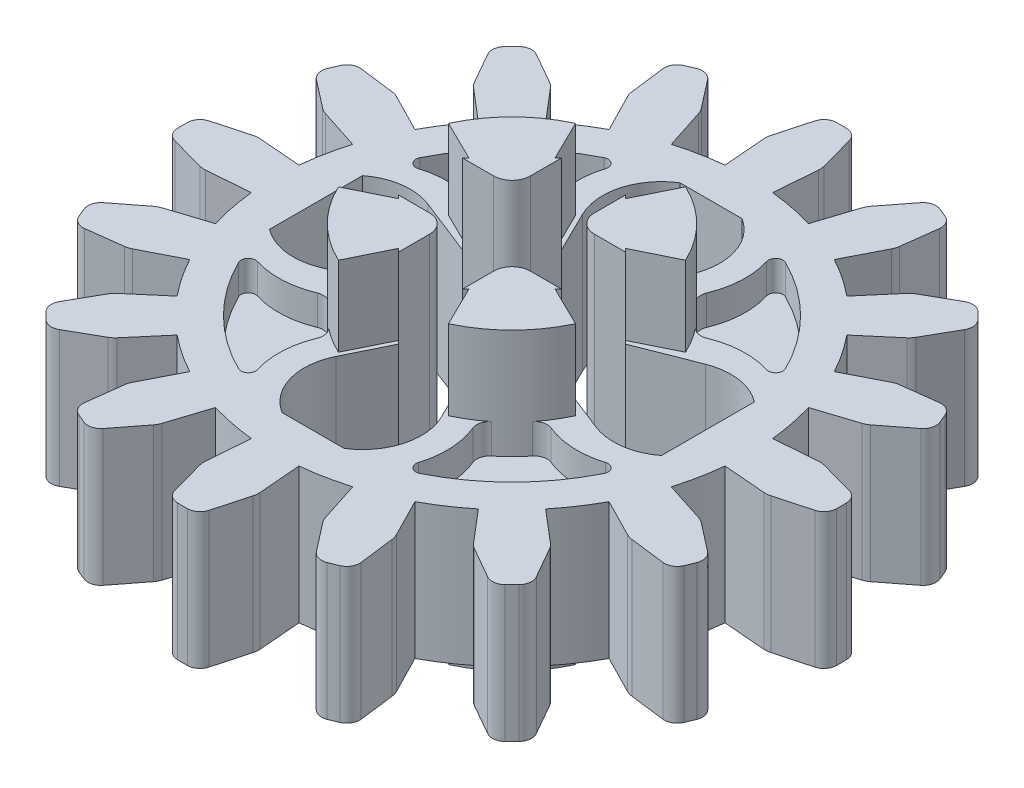
from build123d import *

# Parameters (mm, degrees)
BOSS_EXTRUDE1_DEPTH = 3.71
BOSS_EXTRUDE2_DEPTH = 2.1775
BOSS_EXTRUDE3_DEPTH = 2.1775
BOSS_EXTRUDE4_DEPTH = 2.1775
BOSS_EXTRUDE5_DEPTH = 2.1775
BOSS_EXTRUDE6_DEPTH = 2.1775
BOSS_EXTRUDE7_DEPTH = 2.1775
BOSS_EXTRUDE8_DEPTH = 2.1775
BOSS_EXTRUDE9_DEPTH = 2.1775
CUT_EXTRUDE1_DEPTH  = 0.815
CUT_EXTRUDE2_DEPTH  = 0.815
CUT_EXTRUDE3_DEPTH  = 0.815
CUT_EXTRUDE4_DEPTH  = 0.815
CUT_EXTRUDE5_DEPTH  = 0.815
CUT_EXTRUDE6_DEPTH  = 0.815
CUT_EXTRUDE7_DEPTH  = 0.815
CUT_EXTRUDE8_DEPTH  = 0.815
DRAFT1_ANGLE        = -44.305098292
DRAFT2_ANGLE        = -44.305098292
DRAFT3_ANGLE        = -44.305098292
DRAFT4_ANGLE        = -44.305098292
DRAFT5_ANGLE        = -44.305098292
DRAFT6_ANGLE        = -44.305098292
DRAFT7_ANGLE        = -44.305098292
DRAFT8_ANGLE        = -44.305098292
FILLET1_R           = 0.35
FILLET2_R           = 0.5


with BuildPart() as part:
    # Sketch1 → Boss-Extrude1 (new body)
    with BuildSketch(Plane(origin=(0, 1.855, 0), x_dir=(1, 0, 0), z_dir=(0, 1, 0))):
        with BuildLine():
            Line((3.071195766, 8.459772844), (2.258966578, 7.413472196))
            Line((2.258966578, 7.413472196), (1.874452153, 6.223859665))
            ThreePointArc((1.874452153, 6.223859665), (1.268087093, 6.375104323), (0.65, 6.467418341))
            Line((0.65, 6.467418341), (0.75, 7.71362431))
            Line((0.75, 7.71362431), (0.4, 8.991106717))
            ThreePointArc((0.4, 8.991106717), (0, 9), (-0.4, 8.991106717))
            Line((-0.4, 8.991106717), (-0.75, 7.71362431))
            Line((-0.75, 7.71362431), (-0.65, 6.467418341))
            ThreePointArc((-0.65, 6.467418341), (-1.268087093, 6.375104323), (-1.874452153, 6.223859665))
            Line((-1.874452153, 6.223859665), (-2.258966578, 7.413472196))
            Line((-2.258966578, 7.413472196), (-3.071195766, 8.459772844))
            ThreePointArc((-3.071195766, 8.459772844), (-3.444150891, 8.314915793), (-3.810299392, 8.153626098))
            Line((-3.810299392, 8.153626098), (-3.644785876, 6.839447047))
            Line((-3.644785876, 6.839447047), (-3.075495545, 5.726371203))
            ThreePointArc((-3.075495545, 5.726371203), (-3.611206515, 5.40455248), (-4.113535958, 5.032774774))
            Line((-4.113535958, 5.032774774), (-4.924025971, 5.984686143))
            Line((-4.924025971, 5.984686143), (-6.074829818, 6.640515243))
            ThreePointArc((-6.074829818, 6.640515243), (-6.363961031, 6.363961031), (-6.640515243, 6.074829818))
            Line((-6.640515243, 6.074829818), (-5.984686143, 4.924025971))
            Line((-5.984686143, 4.924025971), (-5.032774774, 4.113535958))
            ThreePointArc((-5.032774774, 4.113535958), (-5.40455248, 3.611206515), (-5.726371203, 3.075495545))
            Line((-5.726371203, 3.075495545), (-6.839447047, 3.644785876))
            Line((-6.839447047, 3.644785876), (-8.153626098, 3.810299392))
            ThreePointArc((-8.153626098, 3.810299392), (-8.314915793, 3.444150891), (-8.459772844, 3.071195766))
            Line((-8.459772844, 3.071195766), (-7.413472196, 2.258966578))
            Line((-7.413472196, 2.258966578), (-6.223859665, 1.874452153))
            ThreePointArc((-6.223859665, 1.874452153), (-6.375104323, 1.268087093), (-6.467418341, 0.65))
            Line((-6.467418341, 0.65), (-7.71362431, 0.75))
            Line((-7.71362431, 0.75), (-8.991106717, 0.4))
            ThreePointArc((-8.991106717, 0.4), (-9, 0), (-8.991106717, -0.4))
            Line((-8.991106717, -0.4), (-7.71362431, -0.75))
            Line((-7.71362431, -0.75), (-6.467418341, -0.65))
            ThreePointArc((-6.467418341, -0.65), (-6.375104323, -1.268087093), (-6.223859665, -1.874452153))
            Line((-6.223859665, -1.874452153), (-7.413472196, -2.258966578))
            Line((-7.413472196, -2.258966578), (-8.459772844, -3.071195766))
            ThreePointArc((-8.459772844, -3.071195766), (-8.314915793, -3.444150891), (-8.153626098, -3.810299392))
            Line((-8.153626098, -3.810299392), (-6.839447047, -3.644785876))
            Line((-6.839447047, -3.644785876), (-5.726371203, -3.075495545))
            ThreePointArc((-5.726371203, -3.075495545), (-5.40455248, -3.611206515), (-5.032774774, -4.113535958))
            Line((-5.032774774, -4.113535958), (-5.984686143, -4.924025971))
            Line((-5.984686143, -4.924025971), (-6.640515243, -6.074829818))
            ThreePointArc((-6.640515243, -6.074829818), (-6.363961031, -6.363961031), (-6.074829818, -6.640515243))
            Line((-6.074829818, -6.640515243), (-4.924025971, -5.984686143))
            Line((-4.924025971, -5.984686143), (-4.113535958, -5.032774774))
            ThreePointArc((-4.113535958, -5.032774774), (-3.611206515, -5.40455248), (-3.075495545, -5.726371203))
            Line((-3.075495545, -5.726371203), (-3.644785876, -6.839447047))
            Line((-3.644785876, -6.839447047), (-3.810299392, -8.153626098))
            ThreePointArc((-3.810299392, -8.153626098), (-3.444150891, -8.314915793), (-3.071195766, -8.459772844))
            Line((-3.071195766, -8.459772844), (-2.258966578, -7.413472196))
            Line((-2.258966578, -7.413472196), (-1.874452153, -6.223859665))
            ThreePointArc((-1.874452153, -6.223859665), (-1.268087093, -6.375104323), (-0.65, -6.467418341))
            Line((-0.65, -6.467418341), (-0.75, -7.71362431))
            Line((-0.75, -7.71362431), (-0.4, -8.991106717))
            ThreePointArc((-0.4, -8.991106717), (0, -9), (0.4, -8.991106717))
            Line((0.4, -8.991106717), (0.75, -7.71362431))
            Line((0.75, -7.71362431), (0.65, -6.467418341))
            ThreePointArc((0.65, -6.467418341), (1.268087093, -6.375104323), (1.874452153, -6.223859665))
            Line((1.874452153, -6.223859665), (2.258966578, -7.413472196))
            Line((2.258966578, -7.413472196), (3.071195766, -8.459772844))
            ThreePointArc((3.071195766, -8.459772844), (3.444150891, -8.314915793), (3.810299392, -8.153626098))
            Line((3.810299392, -8.153626098), (3.644785876, -6.839447047))
            Line((3.644785876, -6.839447047), (3.075495545, -5.726371203))
            ThreePointArc((3.075495545, -5.726371203), (3.611206515, -5.40455248), (4.113535958, -5.032774774))
            Line((4.113535958, -5.032774774), (4.924025971, -5.984686143))
            Line((4.924025971, -5.984686143), (6.074829818, -6.640515243))
            ThreePointArc((6.074829818, -6.640515243), (6.363961031, -6.363961031), (6.640515243, -6.074829818))
            Line((6.640515243, -6.074829818), (5.984686143, -4.924025971))
            Line((5.984686143, -4.924025971), (5.032774774, -4.113535958))
            ThreePointArc((5.032774774, -4.113535958), (5.40455248, -3.611206515), (5.726371203, -3.075495545))
            Line((5.726371203, -3.075495545), (6.839447047, -3.644785876))
            Line((6.839447047, -3.644785876), (8.153626098, -3.810299392))
            ThreePointArc((8.153626098, -3.810299392), (8.314915793, -3.444150891), (8.459772844, -3.071195766))
            Line((8.459772844, -3.071195766), (7.413472196, -2.258966578))
            Line((7.413472196, -2.258966578), (6.223859665, -1.874452153))
            ThreePointArc((6.223859665, -1.874452153), (6.375104323, -1.268087093), (6.467418341, -0.65))
            Line((6.467418341, -0.65), (7.71362431, -0.75))
            Line((7.71362431, -0.75), (8.991106717, -0.4))
            ThreePointArc((8.991106717, -0.4), (9, 0), (8.991106717, 0.4))
            Line((8.991106717, 0.4), (7.71362431, 0.75))
            Line((7.71362431, 0.75), (6.467418341, 0.65))
            ThreePointArc((6.467418341, 0.65), (6.375104323, 1.268087093), (6.223859665, 1.874452153))
            Line((6.223859665, 1.874452153), (7.413472196, 2.258966578))
            Line((7.413472196, 2.258966578), (8.459772844, 3.071195766))
            ThreePointArc((8.459772844, 3.071195766), (8.314915793, 3.444150891), (8.153626098, 3.810299392))
            Line((8.153626098, 3.810299392), (6.839447047, 3.644785876))
            Line((6.839447047, 3.644785876), (5.726371203, 3.075495545))
            ThreePointArc((5.726371203, 3.075495545), (5.40455248, 3.611206515), (5.032774774, 4.113535958))
            Line((5.032774774, 4.113535958), (5.984686143, 4.924025971))
            Line((5.984686143, 4.924025971), (6.640515243, 6.074829818))
            ThreePointArc((6.640515243, 6.074829818), (6.363961031, 6.363961031), (6.074829818, 6.640515243))
            Line((6.074829818, 6.640515243), (4.924025971, 5.984686143))
            Line((4.924025971, 5.984686143), (4.113535958, 5.032774774))
            ThreePointArc((4.113535958, 5.032774774), (3.611206515, 5.40455248), (3.075495545, 5.726371203))
            Line((3.075495545, 5.726371203), (3.644785876, 6.839447047))
            Line((3.644785876, 6.839447047), (3.810299392, 8.153626098))
            ThreePointArc((3.810299392, 8.153626098), (3.444150891, 8.314915793), (3.071195766, 8.459772844))
        make_face()
        with BuildLine():
            Line((-3.788594059, 1.490521407), (-2.22406722, 0.875))
            Line((-2.22406722, 0.875), (-0.875, 0.875))
            Line((-0.875, 0.875), (-0.875, 2.22406722))
            Line((-0.875, 2.22406722), (-1.437479603, 3.368474429))
            ThreePointArc((-1.437479603, 3.368474429), (-1.540081076, 4.515086664), (-0.847139124, 5.434367977))
            Line((-0.847139124, 5.434367977), (0.847139124, 5.434367977))
            ThreePointArc((0.847139124, 5.434367977), (1.540081076, 4.515086664), (1.437479603, 3.368474429))
            Line((1.437479603, 3.368474429), (0.875, 2.22406722))
            Line((0.875, 2.22406722), (0.875, 0.875))
            Line((0.875, 0.875), (2.22406722, 0.875))
            Line((2.22406722, 0.875), (3.788594059, 1.490521407))
            ThreePointArc((3.788594059, 1.490521407), (4.599107529, 1.585970305), (5.351439887, 1.269681511))
            Line((5.351439887, 1.269681511), (5.351439887, -1.269681511))
            ThreePointArc((5.351439887, -1.269681511), (4.599107529, -1.585970305), (3.788594059, -1.490521407))
            Line((3.788594059, -1.490521407), (2.22406722, -0.875))
            Line((2.22406722, -0.875), (0.875, -0.875))
            Line((0.875, -0.875), (0.875, -2.22406722))
            Line((0.875, -2.22406722), (1.437479603, -3.368474429))
            ThreePointArc((1.437479603, -3.368474429), (1.540081076, -4.515086664), (0.847139124, -5.434367977))
            Line((0.847139124, -5.434367977), (-0.847139124, -5.434367977))
            ThreePointArc((-0.847139124, -5.434367977), (-1.540081076, -4.515086664), (-1.437479603, -3.368474429))
            Line((-1.437479603, -3.368474429), (-0.875, -2.22406722))
            Line((-0.875, -2.22406722), (-0.875, -0.875))
            Line((-0.875, -0.875), (-2.22406722, -0.875))
            Line((-2.22406722, -0.875), (-3.788594059, -1.490521407))
            ThreePointArc((-3.788594059, -1.490521407), (-4.599107529, -1.585970305), (-5.351439887, -1.269681511))
            Line((-5.351439887, -1.269681511), (-5.351439887, 1.269681511))
            ThreePointArc((-5.351439887, 1.269681511), (-4.599107529, 1.585970305), (-3.788594059, 1.490521407))
        make_face(mode=Mode.SUBTRACT)
    extrude(amount=-BOSS_EXTRUDE1_DEPTH)

    # Sketch2 → Boss-Extrude2 (add)
    with BuildSketch(Plane.XZ.offset(1.855)):
        with BuildLine():
            Line((-2.22406722, -1.004322756), (-2.22406722, -0.875))
            Line((-2.22406722, -0.875), (-0.875, -0.875))
            Line((-0.875, -0.875), (-0.875, -2.22406722))
            Line((-0.875, -2.22406722), (-1.004322756, -2.22406722))
            Line((-1.004322756, -2.22406722), (-1.502122, -3.236877356))
            ThreePointArc((-1.502122, -3.236877356), (-2.523266288, -2.523266288), (-3.236877356, -1.502122))
            Line((-3.236877356, -1.502122), (-2.22406722, -1.004322756))
        make_face()
    extrude(amount=BOSS_EXTRUDE2_DEPTH)

    # Sketch3 → Boss-Extrude3 (add)
    with BuildSketch(Plane(origin=(0, 1.855, 0), x_dir=(-1, 0, 0), z_dir=(0, 1, 0))):
        with BuildLine():
            Line((2.22406722, -0.875), (2.22406722, -1.004322756))
            Line((2.22406722, -1.004322756), (3.236877356, -1.502122))
            ThreePointArc((3.236877356, -1.502122), (2.523266288, -2.523266288), (1.502122, -3.236877356))
            Line((1.502122, -3.236877356), (1.004322756, -2.22406722))
            Line((1.004322756, -2.22406722), (0.875, -2.22406722))
            Line((0.875, -2.22406722), (0.875, -0.875))
            Line((0.875, -0.875), (2.22406722, -0.875))
        make_face()
    extrude(amount=BOSS_EXTRUDE3_DEPTH)

    # Sketch4 → Boss-Extrude4 (add)
    with BuildSketch(Plane.XZ.offset(1.855)):
        with BuildLine():
            Line((-1.004322756, 2.22406722), (-0.875, 2.22406722))
            Line((-0.875, 2.22406722), (-0.875, 0.875))
            Line((-0.875, 0.875), (-2.22406722, 0.875))
            Line((-2.22406722, 0.875), (-2.22406722, 1.004322756))
            Line((-2.22406722, 1.004322756), (-3.236877356, 1.502122))
            ThreePointArc((-3.236877356, 1.502122), (-2.523266288, 2.523266288), (-1.502122, 3.236877356))
            Line((-1.502122, 3.236877356), (-1.004322756, 2.22406722))
        make_face()
    extrude(amount=BOSS_EXTRUDE4_DEPTH)

    # Sketch5 → Boss-Extrude5 (add)
    with BuildSketch(Plane(origin=(0, 1.855, 0), x_dir=(-1, 0, 0), z_dir=(0, 1, 0))):
        with BuildLine():
            Line((0.875, 2.22406722), (1.004322756, 2.22406722))
            Line((1.004322756, 2.22406722), (1.502122, 3.236877356))
            ThreePointArc((1.502122, 3.236877356), (2.523266288, 2.523266288), (3.236877356, 1.502122))
            Line((3.236877356, 1.502122), (2.22406722, 1.004322756))
            Line((2.22406722, 1.004322756), (2.22406722, 0.875))
            Line((2.22406722, 0.875), (0.875, 0.875))
            Line((0.875, 0.875), (0.875, 2.22406722))
        make_face()
    extrude(amount=BOSS_EXTRUDE5_DEPTH)

    # Sketch6 → Boss-Extrude6 (add)
    with BuildSketch(Plane.XZ.offset(1.855)):
        with BuildLine():
            Line((2.22406722, 1.004322756), (2.22406722, 0.875))
            Line((2.22406722, 0.875), (0.875, 0.875))
            Line((0.875, 0.875), (0.875, 2.22406722))
            Line((0.875, 2.22406722), (1.004322756, 2.22406722))
            Line((1.004322756, 2.22406722), (1.502122, 3.236877356))
            ThreePointArc((1.502122, 3.236877356), (2.523266288, 2.523266288), (3.236877356, 1.502122))
            Line((3.236877356, 1.502122), (2.22406722, 1.004322756))
        make_face()
    extrude(amount=BOSS_EXTRUDE6_DEPTH)

    # Sketch7 → Boss-Extrude7 (add)
    with BuildSketch(Plane(origin=(0, 1.855, 0), x_dir=(-1, 0, 0), z_dir=(0, 1, 0))):
        with BuildLine():
            Line((-2.22406722, 0.875), (-2.22406722, 1.004322756))
            Line((-2.22406722, 1.004322756), (-3.236877356, 1.502122))
            ThreePointArc((-3.236877356, 1.502122), (-2.523266288, 2.523266288), (-1.502122, 3.236877356))
            Line((-1.502122, 3.236877356), (-1.004322756, 2.22406722))
            Line((-1.004322756, 2.22406722), (-0.875, 2.22406722))
            Line((-0.875, 2.22406722), (-0.875, 0.875))
            Line((-0.875, 0.875), (-2.22406722, 0.875))
        make_face()
    extrude(amount=BOSS_EXTRUDE7_DEPTH)

    # Sketch8 → Boss-Extrude8 (add)
    with BuildSketch(Plane(origin=(0, 1.855, 0), x_dir=(-1, 0, 0), z_dir=(0, 1, 0))):
        with BuildLine():
            Line((-0.875, -2.22406722), (-1.004322756, -2.22406722))
            Line((-1.004322756, -2.22406722), (-1.502122, -3.236877356))
            ThreePointArc((-1.502122, -3.236877356), (-2.523266288, -2.523266288), (-3.236877356, -1.502122))
            Line((-3.236877356, -1.502122), (-2.22406722, -1.004322756))
            Line((-2.22406722, -1.004322756), (-2.22406722, -0.875))
            Line((-2.22406722, -0.875), (-0.875, -0.875))
            Line((-0.875, -0.875), (-0.875, -2.22406722))
        make_face()
    extrude(amount=BOSS_EXTRUDE8_DEPTH)

    # Sketch9 → Boss-Extrude9 (add)
    with BuildSketch(Plane.XZ.offset(1.855)):
        with BuildLine():
            Line((1.004322756, -2.22406722), (0.875, -2.22406722))
            Line((0.875, -2.22406722), (0.875, -0.875))
            Line((0.875, -0.875), (2.22406722, -0.875))
            Line((2.22406722, -0.875), (2.22406722, -1.004322756))
            Line((2.22406722, -1.004322756), (3.236877356, -1.502122))
            ThreePointArc((3.236877356, -1.502122), (2.523266288, -2.523266288), (1.502122, -3.236877356))
            Line((1.502122, -3.236877356), (1.004322756, -2.22406722))
        make_face()
    extrude(amount=BOSS_EXTRUDE9_DEPTH)

    # Sketch10 → Cut-Extrude1 (cut)
    with BuildSketch(Plane(origin=(0, 1.855, 0), x_dir=(-1, 0, 0), z_dir=(0, 1, 0))):
        with BuildLine():
            ThreePointArc((2.950843011, 2.006557013), (3.832674353, 2.287198781), (4.753735255, 2.197571031))
            ThreePointArc((4.753735255, 2.197571031), (4.965100048, 2.259083289), (4.99190412, 2.477579))
            ThreePointArc((4.99190412, 2.477579), (3.940653781, 3.940653781), (2.477579, 4.99190412))
            ThreePointArc((2.477579, 4.99190412), (2.259083289, 4.965100048), (2.197571031, 4.753735255))
            ThreePointArc((2.197571031, 4.753735255), (2.287198781, 3.832674353), (2.006557013, 2.950843011))
            ThreePointArc((2.006557013, 2.950843011), (2.523266288, 2.523266288), (2.950843011, 2.006557013))
        make_face()
    extrude(amount=-CUT_EXTRUDE1_DEPTH, mode=Mode.SUBTRACT)

    # Sketch11 → Cut-Extrude2 (cut)
    with BuildSketch(Plane(origin=(0, 1.855, 0), x_dir=(-1, 0, 0), z_dir=(0, 1, 0))):
        with BuildLine():
            ThreePointArc((2.006557013, -2.950843011), (2.287198781, -3.832674353), (2.197571031, -4.753735255))
            ThreePointArc((2.197571031, -4.753735255), (2.259083289, -4.965100048), (2.477579, -4.99190412))
            ThreePointArc((2.477579, -4.99190412), (3.940653781, -3.940653781), (4.99190412, -2.477579))
            ThreePointArc((4.99190412, -2.477579), (4.965100048, -2.259083289), (4.753735255, -2.197571031))
            ThreePointArc((4.753735255, -2.197571031), (3.832674353, -2.287198781), (2.950843011, -2.006557013))
            ThreePointArc((2.950843011, -2.006557013), (2.523266288, -2.523266288), (2.006557013, -2.950843011))
        make_face()
    extrude(amount=-CUT_EXTRUDE2_DEPTH, mode=Mode.SUBTRACT)

    # Sketch12 → Cut-Extrude3 (cut)
    with BuildSketch(Plane(origin=(0, 1.855, 0), x_dir=(-1, 0, 0), z_dir=(0, 1, 0))):
        with BuildLine():
            ThreePointArc((-2.950843011, -2.006557013), (-3.832674353, -2.287198781), (-4.753735255, -2.197571031))
            ThreePointArc((-4.753735255, -2.197571031), (-4.965100048, -2.259083289), (-4.99190412, -2.477579))
            ThreePointArc((-4.99190412, -2.477579), (-3.940653781, -3.940653781), (-2.477579, -4.99190412))
            ThreePointArc((-2.477579, -4.99190412), (-2.259083289, -4.965100048), (-2.197571031, -4.753735255))
            ThreePointArc((-2.197571031, -4.753735255), (-2.287198781, -3.832674353), (-2.006557013, -2.950843011))
            ThreePointArc((-2.006557013, -2.950843011), (-2.523266288, -2.523266288), (-2.950843011, -2.006557013))
        make_face()
    extrude(amount=-CUT_EXTRUDE3_DEPTH, mode=Mode.SUBTRACT)

    # Sketch13 → Cut-Extrude4 (cut)
    with BuildSketch(Plane.XZ.offset(1.855)):
        with BuildLine():
            ThreePointArc((4.753735255, -2.197571031), (3.832674353, -2.287198781), (2.950843011, -2.006557013))
            ThreePointArc((2.950843011, -2.006557013), (2.523266288, -2.523266288), (2.006557013, -2.950843011))
            ThreePointArc((2.006557013, -2.950843011), (2.287198781, -3.832674353), (2.197571031, -4.753735255))
            ThreePointArc((2.197571031, -4.753735255), (2.259083289, -4.965100048), (2.477579, -4.99190412))
            ThreePointArc((2.477579, -4.99190412), (3.940653781, -3.940653781), (4.99190412, -2.477579))
            ThreePointArc((4.99190412, -2.477579), (4.965100048, -2.259083289), (4.753735255, -2.197571031))
        make_face()
    extrude(amount=-CUT_EXTRUDE4_DEPTH, mode=Mode.SUBTRACT)

    # Sketch14 → Cut-Extrude5 (cut)
    with BuildSketch(Plane.XZ.offset(1.855)):
        with BuildLine():
            ThreePointArc((-4.753735255, 2.197571031), (-3.832674353, 2.287198781), (-2.950843011, 2.006557013))
            ThreePointArc((-2.950843011, 2.006557013), (-2.523266288, 2.523266288), (-2.006557013, 2.950843011))
            ThreePointArc((-2.006557013, 2.950843011), (-2.287198781, 3.832674353), (-2.197571031, 4.753735255))
            ThreePointArc((-2.197571031, 4.753735255), (-2.259083289, 4.965100048), (-2.477579, 4.99190412))
            ThreePointArc((-2.477579, 4.99190412), (-3.940653781, 3.940653781), (-4.99190412, 2.477579))
            ThreePointArc((-4.99190412, 2.477579), (-4.965100048, 2.259083289), (-4.753735255, 2.197571031))
        make_face()
    extrude(amount=-CUT_EXTRUDE5_DEPTH, mode=Mode.SUBTRACT)

    # Sketch15 → Cut-Extrude6 (cut)
    with BuildSketch(Plane.XZ.offset(1.855)):
        with BuildLine():
            ThreePointArc((-2.197571031, -4.753735255), (-2.287198781, -3.832674353), (-2.006557013, -2.950843011))
            ThreePointArc((-2.006557013, -2.950843011), (-2.523266288, -2.523266288), (-2.950843011, -2.006557013))
            ThreePointArc((-2.950843011, -2.006557013), (-3.832674353, -2.287198781), (-4.753735255, -2.197571031))
            ThreePointArc((-4.753735255, -2.197571031), (-4.965100048, -2.259083289), (-4.99190412, -2.477579))
            ThreePointArc((-4.99190412, -2.477579), (-3.940653781, -3.940653781), (-2.477579, -4.99190412))
            ThreePointArc((-2.477579, -4.99190412), (-2.259083289, -4.965100048), (-2.197571031, -4.753735255))
        make_face()
    extrude(amount=-CUT_EXTRUDE6_DEPTH, mode=Mode.SUBTRACT)

    # Sketch16 → Cut-Extrude7 (cut)
    with BuildSketch(Plane.XZ.offset(1.855)):
        with BuildLine():
            ThreePointArc((2.197571031, 4.753735255), (2.287198781, 3.832674353), (2.006557013, 2.950843011))
            ThreePointArc((2.006557013, 2.950843011), (2.523266288, 2.523266288), (2.950843011, 2.006557013))
            ThreePointArc((2.950843011, 2.006557013), (3.832674353, 2.287198781), (4.753735255, 2.197571031))
            ThreePointArc((4.753735255, 2.197571031), (4.965100048, 2.259083289), (4.99190412, 2.477579))
            ThreePointArc((4.99190412, 2.477579), (3.940653781, 3.940653781), (2.477579, 4.99190412))
            ThreePointArc((2.477579, 4.99190412), (2.259083289, 4.965100048), (2.197571031, 4.753735255))
        make_face()
    extrude(amount=-CUT_EXTRUDE7_DEPTH, mode=Mode.SUBTRACT)

    # Sketch17 → Cut-Extrude8 (cut)
    with BuildSketch(Plane(origin=(0, 1.855, 0), x_dir=(-1, 0, 0), z_dir=(0, 1, 0))):
        with BuildLine():
            ThreePointArc((-2.006557013, 2.950843011), (-2.287198781, 3.832674353), (-2.197571031, 4.753735255))
            ThreePointArc((-2.197571031, 4.753735255), (-2.259083289, 4.965100048), (-2.477579, 4.99190412))
            ThreePointArc((-2.477579, 4.99190412), (-3.940653781, 3.940653781), (-4.99190412, 2.477579))
            ThreePointArc((-4.99190412, 2.477579), (-4.965100048, 2.259083289), (-4.753735255, 2.197571031))
            ThreePointArc((-4.753735255, 2.197571031), (-3.832674353, 2.287198781), (-2.950843011, 2.006557013))
            ThreePointArc((-2.950843011, 2.006557013), (-2.523266288, 2.523266288), (-2.006557013, 2.950843011))
        make_face()
    extrude(amount=-CUT_EXTRUDE8_DEPTH, mode=Mode.SUBTRACT)

    # Draft1
    draft1_faces = [part.faces().sort_by_distance(p)[0] for p in [
        (0.939661378, 2.94375, 2.22406722),
        (0.939661378, -2.94375, 2.22406722),
    ]]
    draft(draft1_faces, Plane(origin=(0.875, -1.855, 0.875), x_dir=(0, 0, -1), z_dir=(-1, 0, 0)), DRAFT1_ANGLE)

    # Draft2
    draft2_faces = [part.faces().sort_by_distance(p)[0] for p in [
        (2.22406722, -2.94375, 0.939661378),
        (2.22406722, 2.94375, 0.939661378),
    ]]
    draft(draft2_faces, Plane(origin=(2.22406722, -1.855, 0.875), x_dir=(-1, 0, 0), z_dir=(0, 0, -1)), DRAFT2_ANGLE)

    # Draft3
    draft3_faces = [part.faces().sort_by_distance(p)[0] for p in [
        (0.939661378, -2.94375, -2.22406722),
        (0.939661378, 2.94375, -2.22406722),
    ]]
    draft(draft3_faces, Plane(origin=(0.875, -1.855, -2.22406722), x_dir=(0, 0, -1), z_dir=(-1, 0, 0)), DRAFT3_ANGLE)

    # Draft4
    draft4_faces = [part.faces().sort_by_distance(p)[0] for p in [
        (2.22406722, 2.94375, -0.939661378),
        (2.22406722, -2.94375, -0.939661378),
    ]]
    draft(draft4_faces, Plane(origin=(0.875, -1.855, -0.875), x_dir=(1, 0, 0), z_dir=(0, 0, 1)), DRAFT4_ANGLE)

    # Draft5
    draft5_faces = [part.faces().sort_by_distance(p)[0] for p in [
        (-0.939661378, 2.94375, -2.22406722),
        (-0.939661378, -2.94375, -2.22406722),
    ]]
    draft(draft5_faces, Plane(origin=(-0.875, -1.855, -0.875), x_dir=(0, 0, 1), z_dir=(1, 0, 0)), DRAFT5_ANGLE)

    # Draft6
    draft6_faces = [part.faces().sort_by_distance(p)[0] for p in [
        (-2.22406722, -2.94375, -0.939661378),
        (-2.22406722, 2.94375, -0.939661378),
    ]]
    draft(draft6_faces, Plane(origin=(-2.22406722, -1.855, -0.875), x_dir=(1, 0, 0), z_dir=(0, 0, 1)), DRAFT6_ANGLE)

    # Draft7
    draft7_faces = [part.faces().sort_by_distance(p)[0] for p in [
        (-0.939661378, -2.94375, 2.22406722),
        (-0.939661378, 2.94375, 2.22406722),
    ]]
    draft(draft7_faces, Plane(origin=(-0.875, -1.855, 2.22406722), x_dir=(0, 0, 1), z_dir=(1, 0, 0)), DRAFT7_ANGLE)

    # Draft8
    draft8_faces = [part.faces().sort_by_distance(p)[0] for p in [
        (-2.22406722, 2.94375, 0.939661378),
        (-2.22406722, -2.94375, 0.939661378),
    ]]
    draft(draft8_faces, Plane(origin=(-0.875, -1.855, 0.875), x_dir=(-1, 0, 0), z_dir=(0, 0, -1)), DRAFT8_ANGLE)

    # Fillet1
    fillet1_edges = [part.edges().sort_by_distance(p)[0] for p in [
        (3.810299392, 0, -8.153626098),
        (6.074829818, 0, -6.640515243),
        (6.640515243, 0, -6.074829818),
        (8.153626098, 0, -3.810299392),
        (8.459772844, 0, -3.071195766),
        (8.991106717, 0, -0.4),
        (8.991106717, 0, 0.4),
        (8.459772844, 0, 3.071195766),
        (8.153626098, 0, 3.810299392),
        (6.640515243, 0, 6.074829818),
        (6.074829818, 0, 6.640515243),
        (3.810299392, 0, 8.153626098),
        (3.071195766, 0, 8.459772844),
        (0.4, 0, 8.991106717),
        (-0.4, 0, 8.991106717),
        (-3.071195766, 0, 8.459772844),
        (-3.810299392, 0, 8.153626098),
        (-6.074829818, 0, 6.640515243),
        (-6.640515243, 0, 6.074829818),
        (-8.153626098, 0, 3.810299392),
        (-8.459772844, 0, 3.071195766),
        (-8.991106717, 0, 0.4),
        (-8.991106717, 0, -0.4),
        (-8.459772844, 0, -3.071195766),
        (-8.153626098, 0, -3.810299392),
        (-6.640515243, 0, -6.074829818),
        (-6.074829818, 0, -6.640515243),
        (-3.810299392, 0, -8.153626098),
        (-3.071195766, 0, -8.459772844),
        (-0.4, 0, -8.991106717),
        (0.4, 0, -8.991106717),
        (3.071195766, 0, -8.459772844),
        (-2.950843011, 1.4475, 2.006557013),
        (-2.006557013, 1.4475, 2.950843011),
        (-2.006557013, 1.4475, -2.950843011),
        (-2.950843011, 1.4475, -2.006557013),
        (2.950843011, 1.4475, -2.006557013),
        (2.006557013, 1.4475, -2.950843011),
        (2.006557013, -1.4475, -2.950843011),
        (2.950843011, -1.4475, -2.006557013),
        (-2.006557013, -1.4475, 2.950843011),
        (-2.950843011, -1.4475, 2.006557013),
        (-2.950843011, -1.4475, -2.006557013),
        (-2.006557013, -1.4475, -2.950843011),
        (2.950843011, -1.4475, 2.006557013),
        (2.006557013, -1.4475, 2.950843011),
        (2.006557013, 1.4475, 2.950843011),
        (2.950843011, 1.4475, 2.006557013),
    ]]
    fillet(fillet1_edges, radius=FILLET1_R)

    # Fillet2
    fillet2_edges = [part.edges().sort_by_distance(p)[0] for p in [
        (3.644785876, 0, -6.839447047),
        (4.924025971, 0, -5.984686143),
        (5.984686143, 0, -4.924025971),
        (6.839447047, 0, -3.644785876),
        (7.413472196, 0, -2.258966578),
        (7.71362431, 0, -0.75),
        (7.71362431, 0, 0.75),
        (7.413472196, 0, 2.258966578),
        (6.839447047, 0, 3.644785876),
        (5.984686143, 0, 4.924025971),
        (4.924025971, 0, 5.984686143),
        (3.644785876, 0, 6.839447047),
        (2.258966578, 0, 7.413472196),
        (0.75, 0, 7.71362431),
        (-0.75, 0, 7.71362431),
        (-2.258966578, 0, 7.413472196),
        (-3.644785876, 0, 6.839447047),
        (-4.924025971, 0, 5.984686143),
        (-5.984686143, 0, 4.924025971),
        (-6.839447047, 0, 3.644785876),
        (-7.413472196, 0, 2.258966578),
        (-7.71362431, 0, 0.75),
        (-7.71362431, 0, -0.75),
        (-7.413472196, 0, -2.258966578),
        (-6.839447047, 0, -3.644785876),
        (-5.984686143, 0, -4.924025971),
        (-4.924025971, 0, -5.984686143),
        (-3.644785876, 0, -6.839447047),
        (-2.258966578, 0, -7.413472196),
        (-0.75, 0, -7.71362431),
        (0.75, 0, -7.71362431),
        (2.258966578, 0, -7.413472196),
        (-0.875, 0, -0.875),
        (0.875, 0, -0.875),
        (0.875, 0, 0.875),
        (-0.875, 0, 0.875),
    ]]
    fillet(fillet2_edges, radius=FILLET2_R)


solid = part.part
